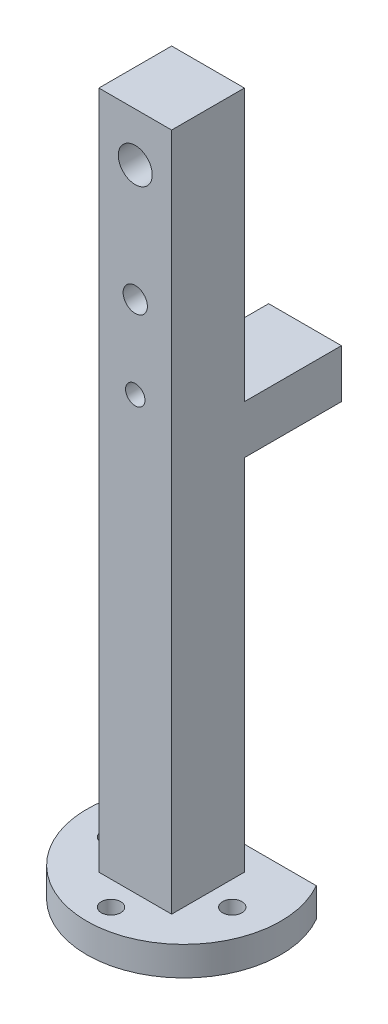
from build123d import *

# Parameters (mm, degrees)
SKETCH1_W           = 19.05
SKETCH1_H           = 19.05
BOSS_EXTRUDE1_DEPTH = 177.8
BOSS_EXTRUDE2_DEPTH = 7.62
SKETCH3_R           = 2.54
CUT_EXTRUDE1_DEPTH  = 7.62
SKETCH4_R           = 4.445
CUT_EXTRUDE2_DEPTH  = 19.05
SKETCH5_R           = 3.175
SKETCH5_R_2         = 2.54
CUT_EXTRUDE3_DEPTH  = 38.1
SKETCH6_W           = 19.05
SKETCH6_H           = 12.7
BOSS_EXTRUDE3_DEPTH = 25.4


with BuildPart() as part:
    # Sketch1 → Boss-Extrude1 (new body)
    with BuildSketch(Plane(origin=(0, 0, 0), x_dir=(1, 0, 0), z_dir=(0, 1, 0))):
        with Locations((9.525, 9.525)):
            Rectangle(SKETCH1_W, SKETCH1_H)
    extrude(amount=BOSS_EXTRUDE1_DEPTH)

    # Sketch2 → Boss-Extrude2 (add)
    with BuildSketch(Plane.XZ):
        with BuildLine():
            ThreePointArc((34.925, -12.7), (2.950996254, 11.834515988), (-12.472045256, -25.4))
            Line((-12.472045256, -25.4), (31.522045256, -25.4))
            ThreePointArc((31.522045256, -25.4), (34.059515988, -19.274003746), (34.925, -12.7))
        make_face()
    extrude(amount=BOSS_EXTRUDE2_DEPTH)

    # Sketch3 → Cut-Extrude1 (cut)
    with BuildSketch(Plane(origin=(0, 0, 0), x_dir=(1, 0, 0), z_dir=(0, 1, 0))):
        with Locations((-6.35, 9.525)):
            Circle(SKETCH3_R)
        with Locations((25.4, 9.525)):
            Circle(SKETCH3_R)
        with Locations((9.525, -6.35)):
            Circle(SKETCH3_R)
    extrude(amount=-CUT_EXTRUDE1_DEPTH, mode=Mode.SUBTRACT)

    # Sketch4 → Cut-Extrude2 (cut)
    with BuildSketch(Plane(origin=(0, 0, -19.05), x_dir=(-1, 0, 0), z_dir=(0, 0, -1))):
        with Locations((-9.525, 165.1)):
            Circle(SKETCH4_R)
    extrude(amount=-CUT_EXTRUDE2_DEPTH, mode=Mode.SUBTRACT)

    # Sketch5 → Cut-Extrude3 (cut)
    with BuildSketch(Plane(origin=(0, 0, -19.05), x_dir=(-1, 0, 0), z_dir=(0, 0, -1))):
        with Locations((-9.525, 134.62)):
            Circle(SKETCH5_R)
        with Locations((-9.525, 113.03)):
            Circle(SKETCH5_R_2)
    extrude(amount=-CUT_EXTRUDE3_DEPTH, mode=Mode.SUBTRACT)

    # Sketch6 → Boss-Extrude3 (add)
    with BuildSketch(Plane(origin=(0, 0, -19.05), x_dir=(-1, 0, 0), z_dir=(0, 0, -1))):
        with Locations((-9.525, 100.33)):
            Rectangle(SKETCH6_W, SKETCH6_H)
    extrude(amount=BOSS_EXTRUDE3_DEPTH)


solid = part.part
